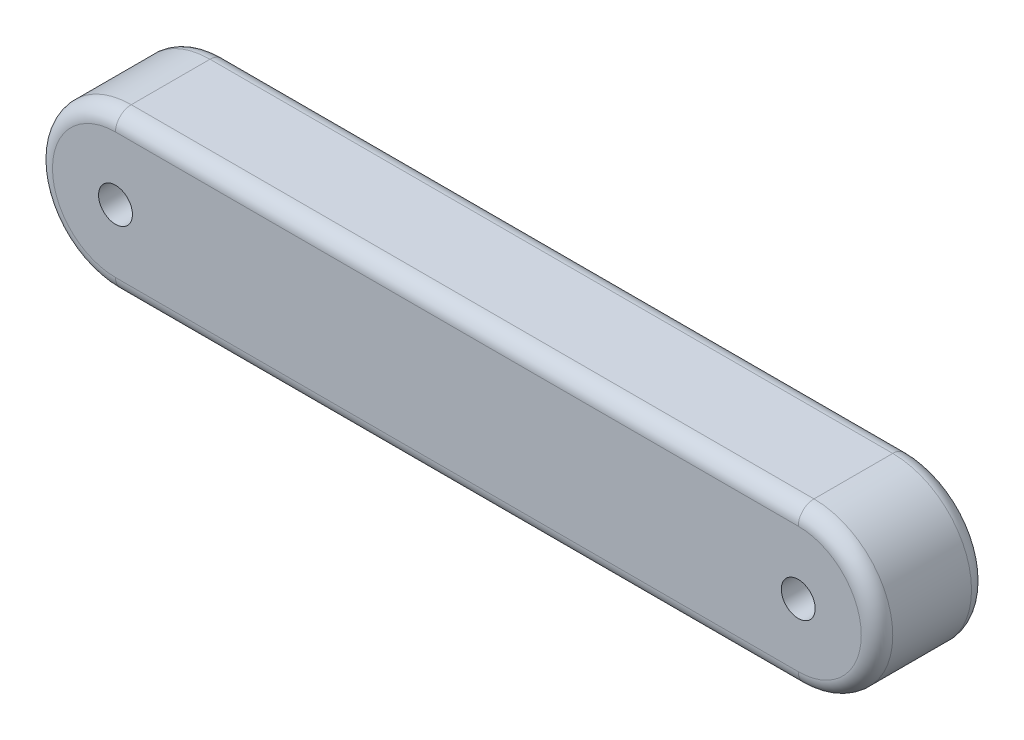
from build123d import *

# Parameters (mm, degrees)
SKETCH1_R           = 2.15
BOSS_EXTRUDE1_DEPTH = 14
FILLET1_R           = 2


with BuildPart() as part:
    # Sketch1 → Boss-Extrude1 (new body)
    with BuildSketch(Plane.XY):
        with BuildLine():
            Line((-43.345, -10), (43.345, -10))
            ThreePointArc((43.345, -10), (53.345, 0), (43.345, 10))
            Line((43.345, 10), (-43.345, 10))
            ThreePointArc((-43.345, 10), (-53.345, 0), (-43.345, -10))
        make_face()
        with Locations((-43.345, 0)):
            Circle(SKETCH1_R, mode=Mode.SUBTRACT)
        with Locations((43.345, 0)):
            Circle(SKETCH1_R, mode=Mode.SUBTRACT)
    extrude(amount=BOSS_EXTRUDE1_DEPTH)

    # Fillet1
    fillet1_edges = [part.edges().sort_by_distance(p)[0] for p in [
        (-53.345, 0, 14),
        (0, -10, 14),
        (53.345, 0, 14),
        (0, -10, 0),
        (-53.345, 0, 0),
        (0, 10, 0),
        (53.345, 0, 0),
        (0, 10, 14),
    ]]
    fillet(fillet1_edges, radius=FILLET1_R)


solid = part.part
